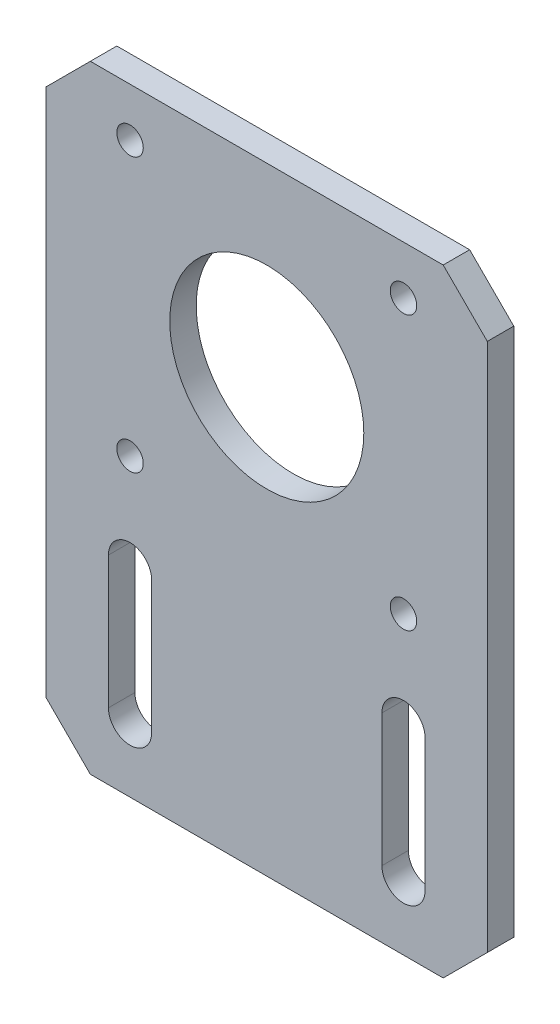
from build123d import *

# Parameters (mm, degrees)
SKETCH1_R           = 11
SKETCH1_R_2         = 1.5
BOSS_EXTRUDE1_DEPTH = 3


with BuildPart() as part:
    # Sketch1 → Boss-Extrude1 (new body)
    with BuildSketch(Plane.XY):
        Polygon((20, -49), (-20, -49), (-25, -44), (-25, 16), (-20, 21), (20, 21), (25, 16), (25, -44), align=None)
        Circle(SKETCH1_R, mode=Mode.SUBTRACT)
        with Locations((-15.5, 15.5)):
            Circle(SKETCH1_R_2, mode=Mode.SUBTRACT)
        with Locations((15.5, 15.5)):
            Circle(SKETCH1_R_2, mode=Mode.SUBTRACT)
        with Locations((-15.5, -15.5)):
            Circle(SKETCH1_R_2, mode=Mode.SUBTRACT)
        with Locations((15.5, -15.5)):
            Circle(SKETCH1_R_2, mode=Mode.SUBTRACT)
        with BuildLine():
            Line((-13.05, -26.45), (-13.05, -41.45))
            ThreePointArc((-13.05, -41.45), (-15.5, -43.9), (-17.95, -41.45))
            Line((-17.95, -41.45), (-17.95, -26.45))
            ThreePointArc((-17.95, -26.45), (-15.5, -24), (-13.05, -26.45))
        make_face(mode=Mode.SUBTRACT)
        with BuildLine():
            Line((13.05, -26.45), (13.05, -41.45))
            ThreePointArc((13.05, -41.45), (15.5, -43.9), (17.95, -41.45))
            Line((17.95, -41.45), (17.95, -26.45))
            ThreePointArc((17.95, -26.45), (15.5, -24), (13.05, -26.45))
        make_face(mode=Mode.SUBTRACT)
    extrude(amount=BOSS_EXTRUDE1_DEPTH)


solid = part.part
